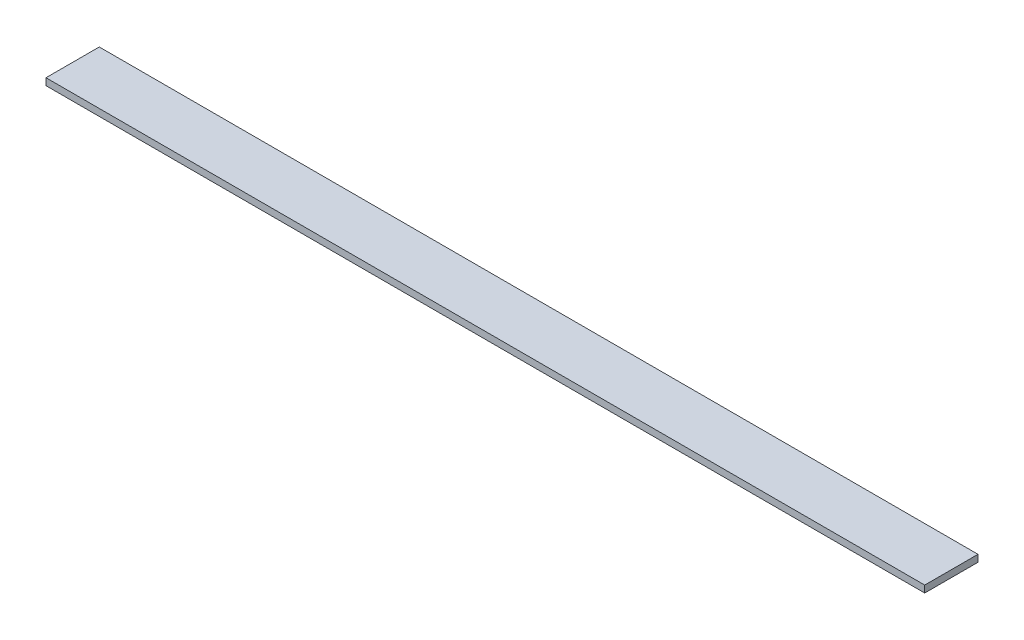
from build123d import *

# Parameters (mm, degrees)
SKETCH1_W           = 19.558
SKETCH1_H           = 2.54
BOSS_EXTRUDE1_DEPTH = 322.58


with BuildPart() as part:
    # Sketch1 → Boss-Extrude1 (new body)
    with BuildSketch(Plane(origin=(0, 0, 0), x_dir=(0, 0, -1), z_dir=(1, 0, 0))):
        with Locations((9.779, 1.27)):
            Rectangle(SKETCH1_W, SKETCH1_H)
    extrude(amount=BOSS_EXTRUDE1_DEPTH)


solid = part.part
